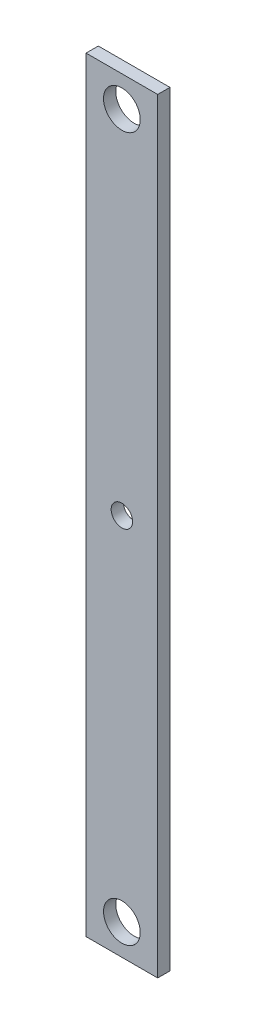
from build123d import *

# Parameters (mm, degrees)
SKETCH1_W           = 11.7
SKETCH1_H           = 125
BOSS_EXTRUDE1_DEPTH = 1
SKETCH2_R           = 3
CUT_EXTRUDE1_DEPTH  = 3
SKETCH3_R           = 1.75
CUT_EXTRUDE2_DEPTH  = 10


with BuildPart() as part:
    # Sketch1 → Boss-Extrude1 (new body, symmetric)
    with BuildSketch(Plane.XY):
        Rectangle(SKETCH1_W, SKETCH1_H)
    extrude(amount=BOSS_EXTRUDE1_DEPTH, both=True)

    # Sketch2 → Cut-Extrude1 (cut, through all)
    with BuildSketch(Plane.XY.offset(1)):
        with Locations((0, 57.5)):
            Circle(SKETCH2_R)
        with Locations((0, -57.5)):
            Circle(SKETCH2_R)
    extrude(amount=-CUT_EXTRUDE1_DEPTH, mode=Mode.SUBTRACT)

    # Sketch3 → Cut-Extrude2 (cut)
    with BuildSketch(Plane.XY.offset(1)):
        Circle(SKETCH3_R)
    extrude(amount=-CUT_EXTRUDE2_DEPTH, mode=Mode.SUBTRACT)


solid = part.part
